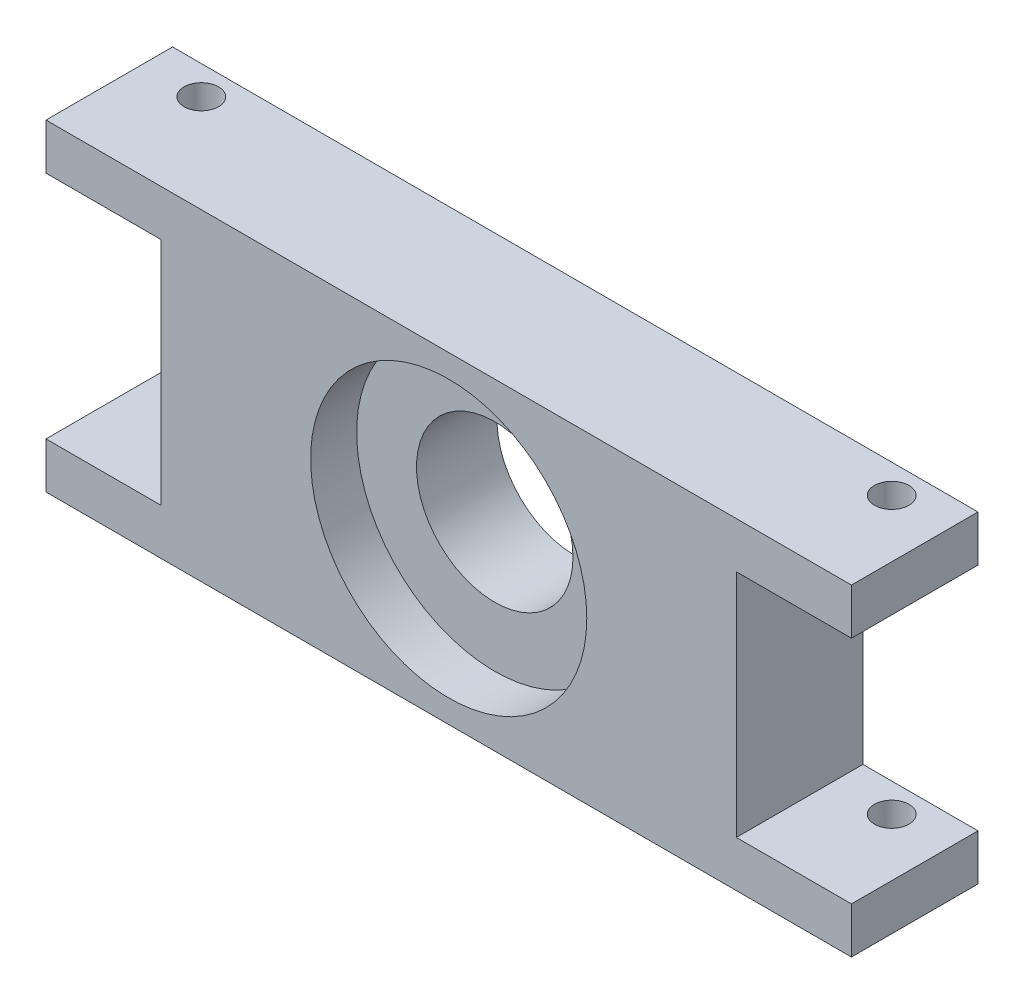
from build123d import *

# Parameters (mm, degrees)
ESQUISSE1_W             = 70
ESQUISSE1_H             = 28
BOSS_EXTRU_1_DEPTH      = 11
ESQUISSE2_R             = 1.5
ENL_V_MAT_EXTRU_1_DEPTH = 29
ESQUISSE3_R             = 6.8
ENL_V_MAT_EXTRU_2_DEPTH = 12
ESQUISSE4_R             = 12
ENL_V_MAT_EXTRU_3_DEPTH = 4
ESQUISSE5_W             = 10
ESQUISSE5_H             = 20
ENL_V_MAT_EXTRU_4_DEPTH = 12
ESQUISSE6_W             = 10
ESQUISSE6_H             = 20
ENL_V_MAT_EXTRU_5_DEPTH = 12


with BuildPart() as part:
    # Esquisse1 → Boss.-Extru.1 (new body)
    with BuildSketch(Plane.XY):
        Rectangle(ESQUISSE1_W, ESQUISSE1_H)
    extrude(amount=BOSS_EXTRU_1_DEPTH)

    # Esquisse2 → Enlèv. mat.-Extru.1 (cut, through all)
    with BuildSketch(Plane(origin=(0, 14, 0), x_dir=(1, 0, 0), z_dir=(0, 1, 0))):
        with Locations((30, -2.5)):
            Circle(ESQUISSE2_R)
        with Locations((-30, -2.5)):
            Circle(ESQUISSE2_R)
    extrude(amount=-ENL_V_MAT_EXTRU_1_DEPTH, mode=Mode.SUBTRACT)

    # Esquisse3 → Enlèv. mat.-Extru.2 (cut, through all)
    with BuildSketch(Plane.XY.offset(11)):
        Circle(ESQUISSE3_R)
    extrude(amount=-ENL_V_MAT_EXTRU_2_DEPTH, mode=Mode.SUBTRACT)

    # Esquisse4 → Enlèv. mat.-Extru.3 (cut)
    with BuildSketch(Plane.XY.offset(11)):
        Circle(ESQUISSE4_R)
    extrude(amount=-ENL_V_MAT_EXTRU_3_DEPTH, mode=Mode.SUBTRACT)

    # Esquisse5 → Enlèv. mat.-Extru.4 (cut, through all)
    with BuildSketch(Plane.XY.offset(11)):
        with Locations((-30, 0)):
            Rectangle(ESQUISSE5_W, ESQUISSE5_H)
    extrude(amount=-ENL_V_MAT_EXTRU_4_DEPTH, mode=Mode.SUBTRACT)

    # Esquisse6 → Enlèv. mat.-Extru.5 (cut, through all)
    with BuildSketch(Plane.XY.offset(11)):
        with Locations((30, 0)):
            Rectangle(ESQUISSE6_W, ESQUISSE6_H)
    extrude(amount=-ENL_V_MAT_EXTRU_5_DEPTH, mode=Mode.SUBTRACT)


solid = part.part
